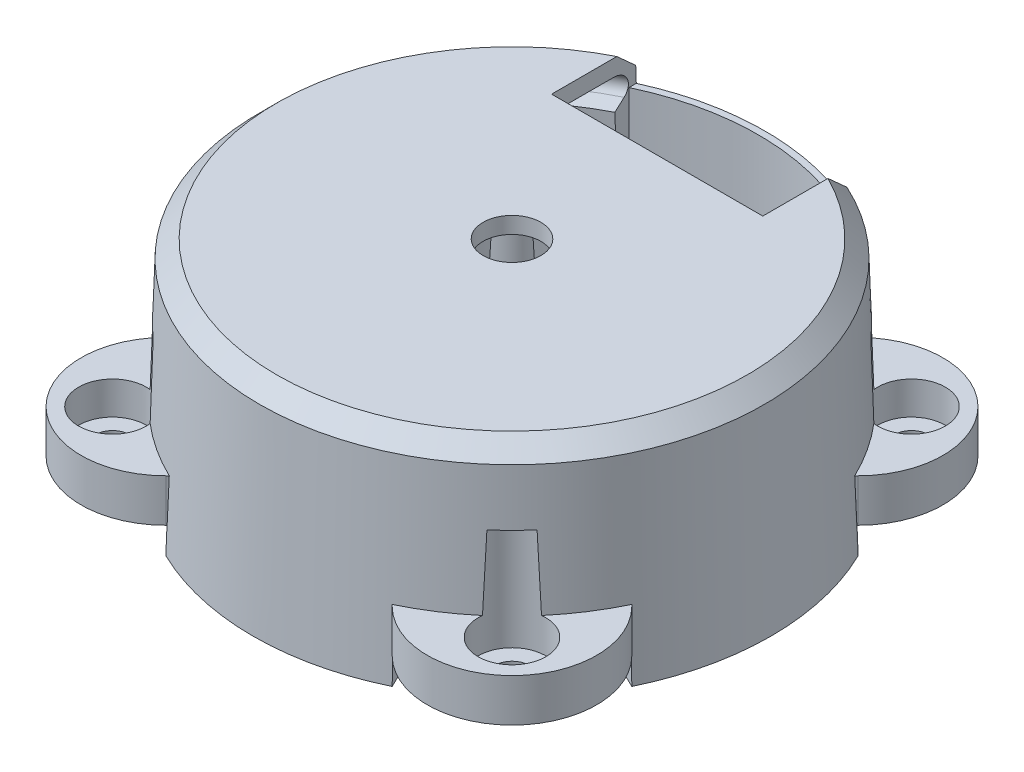
from build123d import *
from build123d.topology import SkipClean

# Parameters (mm, degrees)
BOSS_EXTRUDE1_REACH = 27.729
CIRPATTERN1_COUNT   = 8
SKETCH5_R           = 1.75
CUT_EXTRUDE1_DEPTH  = 26.238462759
SKETCH6_W           = 12.8
SKETCH6_H           = 6.9
CUT_EXTRUDE3_DEPTH  = 2
CUT_EXTRUDE4_DEPTH  = 25.778619861
SKETCH8_R           = 2.5
BOSS_EXTRUDE2_DEPTH = 1
CHAMFER1_SIZE       = 0.4
CHAMFER2_SIZE       = 1
CHAMFER2_SIZE2      = 1.035057312
BOSS_EXTRUDE3_START = -1.6
BOSS_EXTRUDE3_DEPTH = 2.6
SKETCH9_3_R         = 1.05
CUT_EXTRUDE5_DEPTH  = 26.728971997
CUT_EXTRUDE6_START  = -2.2
SKETCH9_4_R         = 2.05
CUT_EXTRUDE6_DEPTH  = 6.4
CUT_EXTRUDE8_DEPTH  = 25.958766121
CIRPATTERN2_COUNT   = 4
CUT_EXTRUDE7_DEPTH  = 1


with BuildPart() as part:
    # Sketch3 → Revolve1 (revolve)
    with BuildSketch(Plane.XY, mode=Mode.PRIVATE) as revolve1_sk:
        Polygon((-14.5, 0), (-14.1, 12), (0, 12), (0, 13), (-15.266666667, 13), (-15.7, 0), align=None)
    revolve(revolve1_sk.sketch.rotate(Axis((0, 12, 0), (0, 1, 0)), 180), axis=Axis((0, 12, 0), (0, 1, 0)))

    # Sketch4 → Boss-Extrude1 (add, up to next)
    with BuildSketch(Plane.XZ, mode=Mode.PRIVATE) as boss_extrude1_sk1:
        with BuildLine():
            ThreePointArc((-1.028368794, 14.463487049), (0, 14.5), (1.028368794, 14.463487049))
            ThreePointArc((1.028368794, 14.463487049), (0, 14.1), (-1.028368794, 14.463487049))
        make_face()
    boss_extrude1_tool1 = extrude(boss_extrude1_sk1.sketch, amount=-BOSS_EXTRUDE1_REACH, mode=Mode.PRIVATE) - part.part
    boss_extrude1 = boss_extrude1_tool1.solids().sort_by_distance((0, 0, 14.331035))[0]
    add(boss_extrude1)

    # CirPattern1: Boss-Extrude1 ×8 about axis
    cirpattern1_axis = Axis((0, 0, 0), (0, 1, 0))
    for i in range(1, CIRPATTERN1_COUNT):
        add(boss_extrude1.rotate(cirpattern1_axis, i * 360 / CIRPATTERN1_COUNT))

    # Sketch5 → Cut-Extrude1 (cut, through all)
    with BuildSketch(Plane.XZ.offset(-12)):
        Circle(SKETCH5_R)
    extrude(amount=-CUT_EXTRUDE1_DEPTH, mode=Mode.SUBTRACT)

    # Sketch6 → Cut-Extrude3 (cut)
    with BuildSketch(Plane(origin=(0, 13, 0), x_dir=(1, 0, 0), z_dir=(0, 1, 0))):
        with Locations((0, 12.25)):
            Rectangle(SKETCH6_W, SKETCH6_H)
    extrude(amount=-CUT_EXTRUDE3_DEPTH, mode=Mode.SUBTRACT)

    # Sketch7 → Cut-Extrude4 (cut, through all)
    with BuildSketch(Plane(origin=(0, 11, 0), x_dir=(1, 0, 0), z_dir=(0, 1, 0))):
        with BuildLine():
            Line((6.4, 13.492384683), (6.4, 8.8))
            Line((6.4, 8.8), (-6.4, 8.8))
            Line((-6.4, 8.8), (-6.4, 13.492384683))
            ThreePointArc((-6.4, 13.492384683), (0, 14.933333333), (6.4, 13.492384683))
        make_face()
    extrude(amount=-CUT_EXTRUDE4_DEPTH, mode=Mode.SUBTRACT)

    # Sketch8 → Boss-Extrude2 (add)
    with BuildSketch(Plane.XZ.offset(-12)):
        with Locations(Location((0, 10, 0), (0, 0, 180))):
            Circle(SKETCH8_R)
        with Locations(Location((10, 0, 0), (0, 0, 180))):
            Circle(SKETCH8_R)
        with Locations(Location((-10, 0, 0), (0, 0, 180))):
            Circle(SKETCH8_R)
    extrude(amount=BOSS_EXTRUDE2_DEPTH)

    # Chamfer1
    chamfer1_edges = [part.edges().sort_by_distance(p)[0] for p in [
        (2.5, 11, 10),
        (12.5, 11, 0),
        (-7.5, 11, 0),
    ]]
    chamfer(chamfer1_edges, length=CHAMFER1_SIZE)

    # Chamfer2
    chamfer2_edges = [part.edges().sort_by_distance(p)[0] for p in [
        (-8.22692058, 13, 12.860361149),
    ]]
    chamfer2_side = [part.faces().sort_by_distance(p)[0] for p in [
        (12.504892891, 13, -7.999523456),
    ]]
    chamfer(chamfer2_edges, length=CHAMFER2_SIZE, length2=CHAMFER2_SIZE2, reference=chamfer2_side[0])

    # Sketch9 → Boss-Extrude3 (add)
    with BuildSketch(Plane.XZ.offset(BOSS_EXTRUDE3_START)):
        with BuildLine():
            Line((14.121973075, 6.860020152), (13.858206234, 6.596253311))
            Line((13.858206234, 6.596253311), (6.596253311, 13.858206234))
            Line((6.596253311, 13.858206234), (6.860020152, 14.121973075))
            ThreePointArc((6.860020152, 14.121973075), (14.121973075, 14.121973075), (14.121973075, 6.860020152))
        make_face()
    boss_extrude3 = extrude(amount=-BOSS_EXTRUDE3_DEPTH)

    # Sketch9_3 → Cut-Extrude5 (cut, through all)
    with BuildSketch(Plane.XZ):
        with Locations(Location((12.106718748, 12.106718748, 0), (0, 0, 180))):
            Circle(SKETCH9_3_R)
    cut_extrude5 = extrude(amount=-CUT_EXTRUDE5_DEPTH, mode=Mode.SUBTRACT)

    # Sketch9_4 → Cut-Extrude6 (cut)
    with BuildSketch(Plane.XZ.offset(CUT_EXTRUDE6_START)):
        with Locations((12.106718748, 12.106718748)):
            Circle(SKETCH9_4_R)
    cut_extrude6 = extrude(amount=-CUT_EXTRUDE6_DEPTH, mode=Mode.SUBTRACT)

    # Sketch12 → Cut-Extrude8 (cut, through all)
    with BuildSketch(Plane.XZ.offset(-1.6)):
        with BuildLine():
            Line((6.860020152, 14.121973075), (6.160909818, 12.682791105))
            Line((6.160909818, 12.682791105), (12.682791105, 6.160909818))
            Line((12.682791105, 6.160909818), (14.121973075, 6.860020152))
            ThreePointArc((14.121973075, 6.860020152), (11.101576465, 11.101576465), (6.860020152, 14.121973075))
        make_face()
    cut_extrude8 = extrude(amount=CUT_EXTRUDE8_DEPTH, mode=Mode.SUBTRACT)

    # CirPattern2: Boss-Extrude3, Cut-Extrude5, Cut-Extrude6, Cut-Extrude8 ×4 about axis
    cirpattern2_axis = Axis((0, 0, 0), (0, 1, 0))
    add([boss_extrude3.rotate(cirpattern2_axis, i * 360 / CIRPATTERN2_COUNT) for i in range(1, CIRPATTERN2_COUNT)])
    add([cut_extrude5.rotate(cirpattern2_axis, i * 360 / CIRPATTERN2_COUNT) for i in range(1, CIRPATTERN2_COUNT)], mode=Mode.SUBTRACT)
    add([cut_extrude6.rotate(cirpattern2_axis, i * 360 / CIRPATTERN2_COUNT) for i in range(1, CIRPATTERN2_COUNT)], mode=Mode.SUBTRACT)
    add([cut_extrude8.rotate(cirpattern2_axis, i * 360 / CIRPATTERN2_COUNT) for i in range(1, CIRPATTERN2_COUNT)], mode=Mode.SUBTRACT)

    # Sketch10 → Cut-Extrude7 (cut)
    with BuildSketch(Plane.XZ):
        with BuildLine():
            Line((6.860020152, -14.121973075), (6.4, -13.17497991))
            Line((6.4, -13.17497991), (6.4, -13.492384683))
            ThreePointArc((6.4, -13.492384683), (0, -14.933333333), (-6.4, -13.492384683))
            Line((-6.4, -13.492384683), (-6.4, -13.17497991))
            Line((-6.4, -13.17497991), (-6.860020152, -14.121973075))
            ThreePointArc((-6.860020152, -14.121973075), (0, -15.7), (6.860020152, -14.121973075))
        make_face()
    extrude(amount=-CUT_EXTRUDE7_DEPTH, mode=Mode.SUBTRACT)

    # Sketch11 → Cut-Revolve1 (revolve, cut)
    with BuildSketch(Plane.XY, mode=Mode.PRIVATE) as cut_revolve1_sk:
        with BuildLine():
            Line((-14.1, 11.2), (-14.1, 12))
            ThreePointArc((-14.1, 12), (-14.839103626, 11.506146746), (-14.665685425, 10.634314575))
            Line((-14.665685425, 10.634314575), (-14.1, 10.06862915))
            Line((-14.1, 10.06862915), (-14.1, 11.2))
        make_face()
    revolve(cut_revolve1_sk.sketch.rotate(Axis((0, -0.65, 0), (0, 1, 0)), 205.730537362), axis=Axis((0, -0.65, 0), (0, 1, 0)), mode=Mode.SUBTRACT)


solid = part.part
